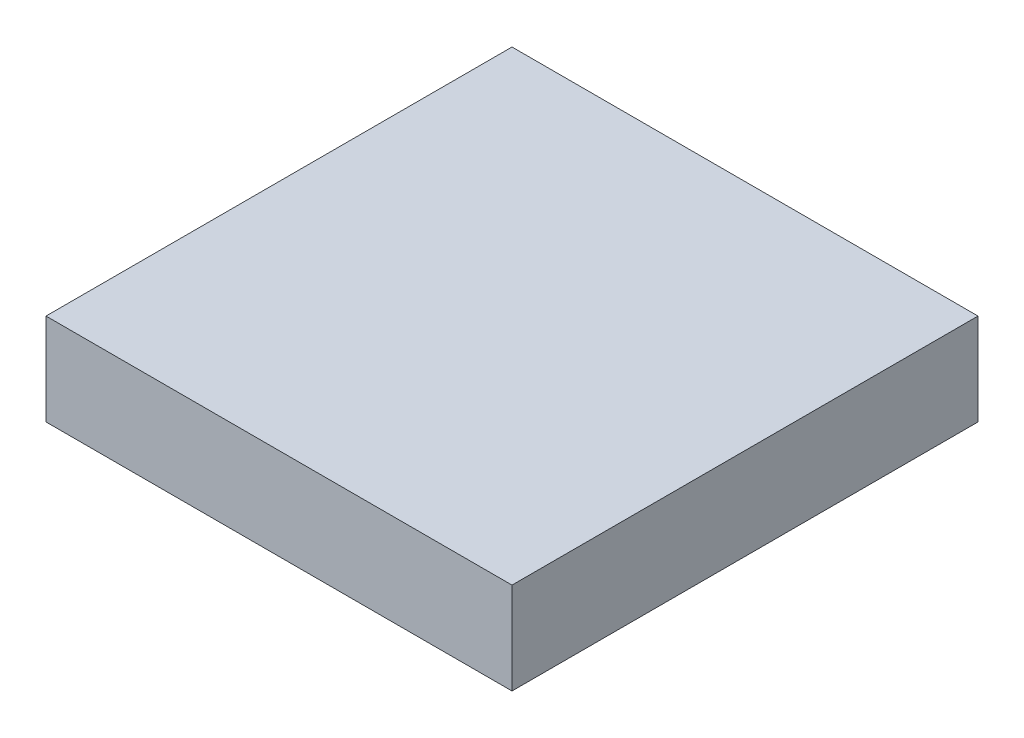
from build123d import *

# Parameters (mm, degrees)
SKETCH1_W           = 152.4
SKETCH1_H           = 152.4
BOSS_EXTRUDE1_DEPTH = 30


with BuildPart() as part:
    # Sketch1 → Boss-Extrude1 (new body)
    with BuildSketch(Plane(origin=(0, 0, 0), x_dir=(1, 0, 0), z_dir=(0, 1, 0))):
        Rectangle(SKETCH1_W, SKETCH1_H)
    extrude(amount=BOSS_EXTRUDE1_DEPTH)


solid = part.part
